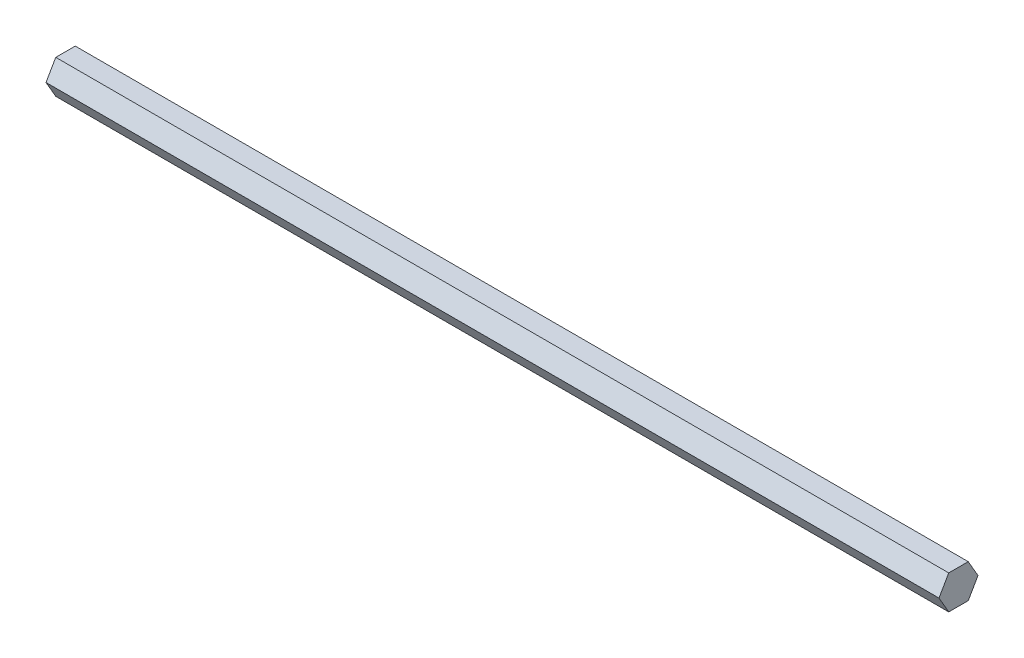
from build123d import *

# Parameters (mm, degrees)
EXTRUDE_1_DEPTH = 370


with BuildPart() as part:
    # Эскиз1 → Бобышка-Вытянуть1 (new body)
    with BuildSketch(Plane(origin=(0, 0, 0), x_dir=(0, 0, -1), z_dir=(1, 0, 0))):
        Polygon((8.082903769, 0), (4.041451884, 7), (-4.041451884, 7), (-8.082903769, 0), (-4.041451884, -7), (4.041451884, -7), align=None)
    extrude(amount=EXTRUDE_1_DEPTH)


solid = part.part
